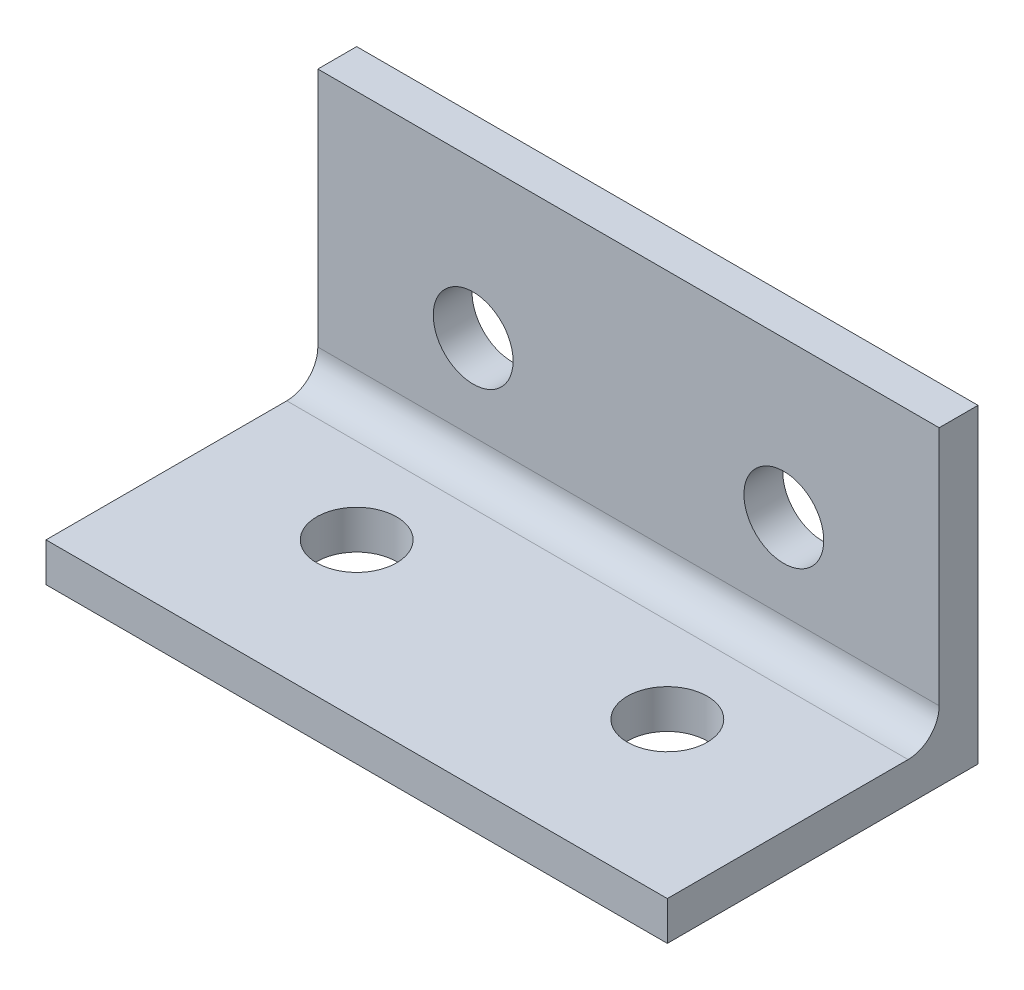
from build123d import *

# Parameters (mm, degrees)
SKETCH1_W           = 50.8
SKETCH1_H           = 25.4
SKETCH1_R           = 3.2639
BOSS_EXTRUDE1_DEPTH = 3.175
SKETCH2_W           = 50.8
SKETCH2_H           = 3.175
BOSS_EXTRUDE2_DEPTH = 22.225
SKETCH3_R           = 3.2639
CUT_EXTRUDE1_DEPTH  = 22.225
FILLET1_R           = 2.54


with BuildPart() as part:
    # Sketch1 → Boss-Extrude1 (new body)
    with BuildSketch(Plane(origin=(0, 0, 0), x_dir=(1, 0, 0), z_dir=(0, 1, 0))):
        with Locations((25.4, 12.7)):
            Rectangle(SKETCH1_W, SKETCH1_H)
        with Locations((12.7, 12.7)):
            Circle(SKETCH1_R, mode=Mode.SUBTRACT)
        with Locations((38.1, 12.7)):
            Circle(SKETCH1_R, mode=Mode.SUBTRACT)
    extrude(amount=BOSS_EXTRUDE1_DEPTH)

    # Sketch2 → Boss-Extrude2 (add)
    with BuildSketch(Plane(origin=(0, 3.175, 0), x_dir=(1, 0, 0), z_dir=(0, 1, 0))):
        with Locations((25.4, 23.8125)):
            Rectangle(SKETCH2_W, SKETCH2_H)
    extrude(amount=BOSS_EXTRUDE2_DEPTH)

    # Sketch3 → Cut-Extrude1 (cut)
    with BuildSketch(Plane.XY.offset(-22.225)):
        with Locations((38.1, 12.7)):
            Circle(SKETCH3_R)
        with Locations((12.7, 12.7)):
            Circle(SKETCH3_R)
    extrude(amount=-CUT_EXTRUDE1_DEPTH, mode=Mode.SUBTRACT)

    # Fillet1
    fillet1_edges = [part.edges().sort_by_distance(p)[0] for p in [
        (25.4, 3.175, -22.225),
    ]]
    fillet(fillet1_edges, radius=FILLET1_R)


solid = part.part
